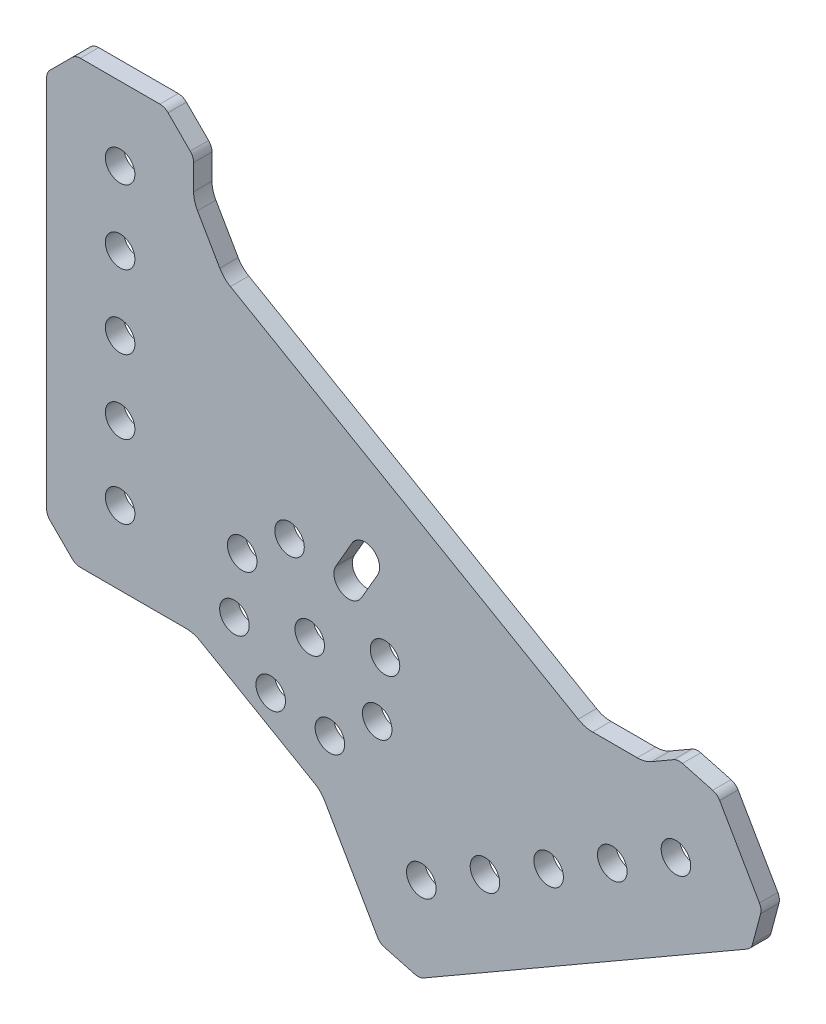
from build123d import *

# Parameters (mm, degrees)
SKETCH1_R           = 2.5527
BOSS_EXTRUDE1_DEPTH = 3.175


with BuildPart() as part:
    # Sketch1 → Boss-Extrude1 (new body)
    with BuildSketch(Plane(origin=(0, 0, 0), x_dir=(-1, 0, 0), z_dir=(0, 0, -1))):
        with BuildLine():
            Line((-4.414213562, 0.585786438), (-0.585786438, 4.414213562))
            ThreePointArc((-0.585786438, 4.414213562), (-0.152240935, 5.06306026), (0, 5.828427125))
            Line((0, 5.828427125), (0, 70.371572875))
            ThreePointArc((0, 70.371572875), (-0.152240935, 71.13693974), (-0.585786438, 71.785786438))
            Line((-0.585786438, 71.785786438), (-4.414213562, 75.614213562))
            ThreePointArc((-4.414213562, 75.614213562), (-5.06306026, 76.047759065), (-5.828427125, 76.2))
            Line((-5.828427125, 76.2), (-19.571572875, 76.2))
            ThreePointArc((-19.571572875, 76.2), (-20.33693974, 76.047759065), (-20.985786438, 75.614213562))
            Line((-20.985786438, 75.614213562), (-24.814213562, 71.785786438))
            ThreePointArc((-24.814213562, 71.785786438), (-25.247759065, 71.13693974), (-25.4, 70.371572875))
            Line((-25.4, 70.371572875), (-25.4, 65.998533312))
            ThreePointArc((-25.4, 65.998533312), (-25.570370869, 64.704438086), (-26.069872981, 63.498533312))
            Line((-26.069872981, 63.498533312), (-29.926279442, 56.819041388))
            ThreePointArc((-29.926279442, 56.819041388), (-30.720872555, 55.783507482), (-31.756406461, 54.988914369))
            Line((-31.756406461, 54.988914369), (-91.840638796, 20.299266656))
            ThreePointArc((-91.840638796, 20.299266656), (-93.04654357, 19.799764543), (-94.340638796, 19.629393675))
            Line((-94.340638796, 19.629393675), (-102.053451717, 19.629393675))
            ThreePointArc((-102.053451717, 19.629393675), (-103.347546942, 19.799764543), (-104.553451717, 20.299266656))
            Line((-104.553451717, 20.299266656), (-108.34061507, 22.485786438))
            ThreePointArc((-108.34061507, 22.485786438), (-109.079562686, 22.736625353), (-109.858253161, 22.685587283))
            Line((-109.858253161, 22.685587283), (-115.08798187, 21.284285698))
            ThreePointArc((-115.08798187, 21.284285698), (-115.787866637, 20.939140726), (-116.302394587, 20.352434046))
            Line((-116.302394587, 20.352434046), (-123.173967462, 8.450520698))
            ThreePointArc((-123.173967462, 8.450520698), (-123.424806377, 7.711573082), (-123.373768307, 6.932882608))
            Line((-123.373768307, 6.932882608), (-121.972466723, 1.703153899))
            ThreePointArc((-121.972466723, 1.703153899), (-121.627321751, 1.003269131), (-121.04061507, 0.488741182))
            Line((-121.04061507, 0.488741182), (-65.14461121, -31.782831694))
            ThreePointArc((-65.14461121, -31.782831694), (-64.405663595, -32.033670609), (-63.62697312, -31.982632539))
            Line((-63.62697312, -31.982632539), (-58.397244411, -30.581330955))
            ThreePointArc((-58.397244411, -30.581330955), (-57.697359643, -30.236185983), (-57.182831694, -29.649479302))
            Line((-57.182831694, -29.649479302), (-48.066918237, -13.860254038))
            ThreePointArc((-48.066918237, -13.860254038), (-47.272325124, -12.824720132), (-46.236791218, -12.030127019))
            Line((-46.236791218, -12.030127019), (-26.560254038, -0.669872981))
            ThreePointArc((-26.560254038, -0.669872981), (-25.354349263, -0.170370869), (-24.060254038, 0))
            Line((-24.060254038, 0), (-5.828427125, 0))
            ThreePointArc((-5.828427125, 0), (-5.06306026, 0.152240935), (-4.414213562, 0.585786438))
        make_face()
        with Locations((-33.792281133, 16.076625677)):
            Circle(SKETCH1_R, mode=Mode.SUBTRACT)
        with Locations((-57.123670933, 2.606241495)):
            Circle(SKETCH1_R, mode=Mode.SUBTRACT)
        with Locations((-32.446584062, 5.855041615)):
            Circle(SKETCH1_R, mode=Mode.SUBTRACT)
        with Locations((-48.944368004, -3.669958385)):
            Circle(SKETCH1_R, mode=Mode.SUBTRACT)
        with Locations((-12.7, 12.7)):
            Circle(SKETCH1_R, mode=Mode.SUBTRACT)
        with Locations((-12.7, 38.1)):
            Circle(SKETCH1_R, mode=Mode.SUBTRACT)
        with Locations((-12.7, 63.5)):
            Circle(SKETCH1_R, mode=Mode.SUBTRACT)
        with Locations((-64.745567884, -17.348522628)):
            Circle(SKETCH1_R, mode=Mode.SUBTRACT)
        with Locations((-86.74261314, -4.648522628)):
            Circle(SKETCH1_R, mode=Mode.SUBTRACT)
        with Locations((-108.739658396, 8.051477372)):
            Circle(SKETCH1_R, mode=Mode.SUBTRACT)
        with Locations((-12.7, 25.4)):
            Circle(SKETCH1_R, mode=Mode.SUBTRACT)
        with Locations((-12.7, 50.8)):
            Circle(SKETCH1_R, mode=Mode.SUBTRACT)
        with Locations((-75.744090512, -10.998522628)):
            Circle(SKETCH1_R, mode=Mode.SUBTRACT)
        with Locations((-97.741135768, 1.701477372)):
            Circle(SKETCH1_R, mode=Mode.SUBTRACT)
        with Locations((-41.971584062, 22.352825557)):
            Circle(SKETCH1_R, mode=Mode.SUBTRACT)
        with Locations((-58.469368004, 12.827825557)):
            Circle(SKETCH1_R, mode=Mode.SUBTRACT)
        with Locations((-45.457976033, 9.341433586)):
            Circle(SKETCH1_R, mode=Mode.SUBTRACT)
        with Locations((-38.722783942, -2.324261314)):
            Circle(SKETCH1_R, mode=Mode.SUBTRACT)
        with BuildLine():
            Line((-54.403871172, 19.730778486), (-57.193679081, 24.562867528))
            ThreePointArc((-57.193679081, 24.562867528), (-56.259326033, 28.049920576), (-52.772272985, 27.115567528))
            Line((-52.772272985, 27.115567528), (-49.982465075, 22.283478486))
            ThreePointArc((-49.982465075, 22.283478486), (-50.916818124, 18.796425438), (-54.403871172, 19.730778486))
        make_face(mode=Mode.SUBTRACT)
    extrude(amount=-BOSS_EXTRUDE1_DEPTH)


solid = part.part
